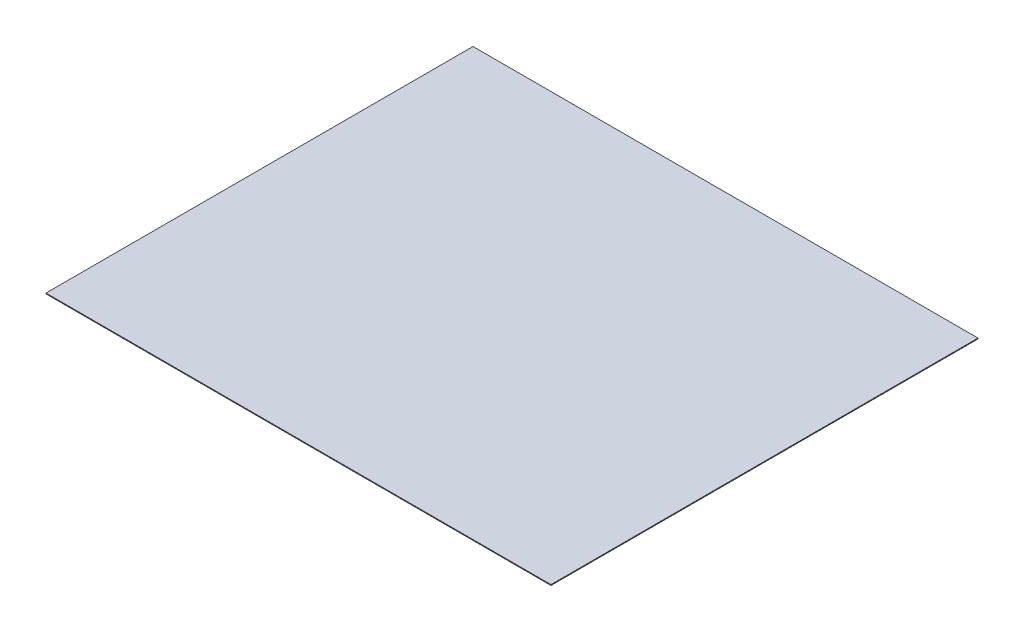
from build123d import *

# Parameters (mm, degrees)
SKETCH1_W           = 641
SKETCH1_H           = 542
BOSS_EXTRUDE1_DEPTH = 1


with BuildPart() as part:
    # Sketch1 → Boss-Extrude1 (new body)
    with BuildSketch(Plane(origin=(0, 0, 0), x_dir=(1, 0, 0), z_dir=(0, 1, 0))):
        Rectangle(SKETCH1_W, SKETCH1_H)
    extrude(amount=BOSS_EXTRUDE1_DEPTH)


solid = part.part
